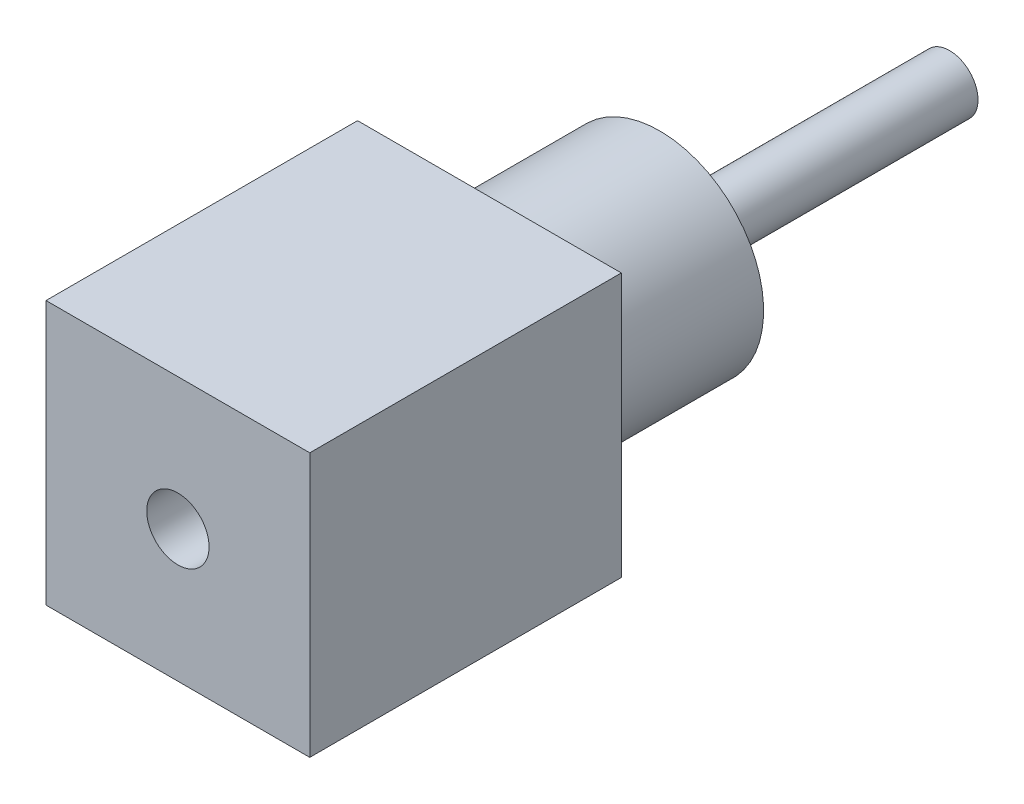
from build123d import *

# Parameters (mm, degrees)
SKETCH1_W           = 2.54
SKETCH1_H           = 2.54
BOSS_EXTRUDE1_DEPTH = 3
SKETCH2_R           = 1
BOSS_EXTRUDE2_DEPTH = 1.64
SKETCH3_R           = 0.275
BOSS_EXTRUDE3_DEPTH = 2.79
SKETCH4_R           = 0.3
CUT_EXTRUDE1_DEPTH  = 3


with BuildPart() as part:
    # Sketch1 → Boss-Extrude1 (new body)
    with BuildSketch(Plane.XY):
        Rectangle(SKETCH1_W, SKETCH1_H)
    extrude(amount=BOSS_EXTRUDE1_DEPTH)

    # Sketch2 → Boss-Extrude2 (add)
    with BuildSketch(Plane(origin=(0, 0, 0), x_dir=(-1, 0, 0), z_dir=(0, 0, -1))):
        Circle(SKETCH2_R)
    extrude(amount=BOSS_EXTRUDE2_DEPTH)

    # Sketch3 → Boss-Extrude3 (add)
    with BuildSketch(Plane(origin=(0, 0, -1.64), x_dir=(-1, 0, 0), z_dir=(0, 0, -1))):
        Circle(SKETCH3_R)
    extrude(amount=BOSS_EXTRUDE3_DEPTH)

    # Sketch4 → Cut-Extrude1 (cut)
    with BuildSketch(Plane.XY.offset(3)):
        Circle(SKETCH4_R)
    extrude(amount=-CUT_EXTRUDE1_DEPTH, mode=Mode.SUBTRACT)


solid = part.part
